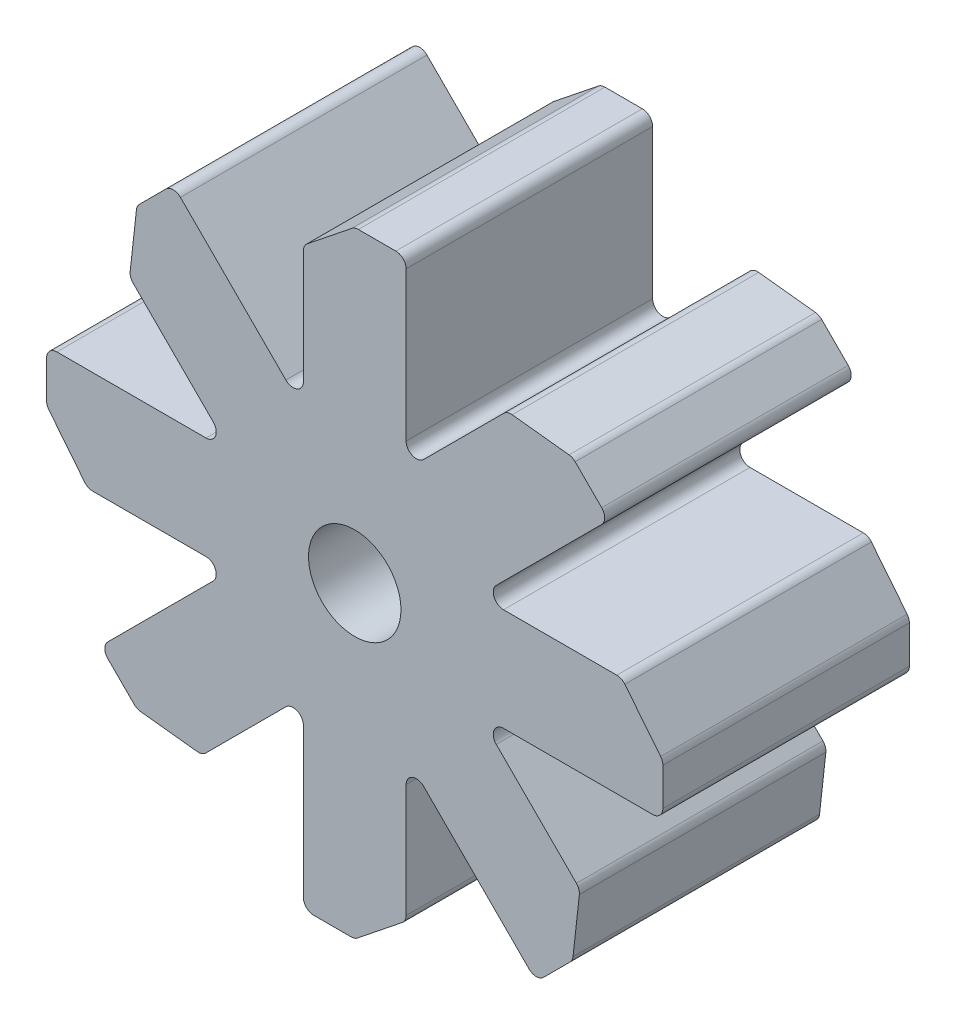
from build123d import *

# Parameters (mm, degrees)
SKETCH3_R           = 2.25
BOSS_EXTRUDE1_DEPTH = 12
INNER_EDGES_R       = 0.5
CUT_EXTRUDE2_DEPTH  = 13
OUTER_EDGES_R       = 0.5


with BuildPart() as part:
    # Sketch3 → Boss-Extrude1 (new body)
    with BuildSketch(Plane.XY):
        Polygon((-2.5, 15), (2.5, 15), (2.5, 6.035533906), (8.838834765, 12.374368671), (12.374368671, 8.838834765), (6.035533906, 2.5), (15, 2.5), (15, -2.5), (6.035533906, -2.5), (12.374368671, -8.838834765), (8.838834765, -12.374368671), (2.5, -6.035533906), (2.5, -15), (-2.5, -15), (-2.5, -6.035533906), (-8.838834765, -12.374368671), (-12.374368671, -8.838834765), (-6.035533906, -2.5), (-15, -2.5), (-15, 2.5), (-6.035533906, 2.5), (-12.374368671, 8.838834765), (-8.838834765, 12.374368671), (-2.5, 6.035533906), align=None)
        Circle(SKETCH3_R, mode=Mode.SUBTRACT)
    extrude(amount=BOSS_EXTRUDE1_DEPTH)

    # Inner Edges
    inner_edges_edges = [part.edges().sort_by_distance(p)[0] for p in [
        (6.035533906, 2.5, 6),
        (6.035533906, -2.5, 6),
        (2.5, -6.035533906, 6),
        (-2.5, -6.035533906, 6),
        (-6.035533906, -2.5, 6),
        (-6.035533906, 2.5, 6),
        (-2.5, 6.035533906, 6),
        (2.5, 6.035533906, 6),
    ]]
    fillet(inner_edges_edges, radius=INNER_EDGES_R)

    # Sketch4 → Cut-Extrude2 (cut, through all)
    with BuildSketch(Plane.XY.offset(12)):
        Polygon((10.960155108, -7.424621202), (10.606601718, -10.606601718), (12.374368671, -8.838834765), align=None)
        Polygon((13, 2.5), (15, 0), (15, 2.5), align=None)
        Polygon((8.838834765, 12.374368671), (7.424621202, 10.960155108), (10.606601718, 10.606601718), align=None)
        Polygon((-2.5, 13), (0, 15), (-2.5, 15), align=None)
        Polygon((-10.960155108, 7.424621202), (-10.606601718, 10.606601718), (-12.374368671, 8.838834765), align=None)
        Polygon((-13, -2.5), (-15, 0), (-15, -2.5), align=None)
        Polygon((-7.424621202, -10.960155108), (-10.606601718, -10.606601718), (-8.838834765, -12.374368671), align=None)
        Polygon((0, -15), (2.5, -15), (2.5, -13), align=None)
    extrude(amount=-CUT_EXTRUDE2_DEPTH, mode=Mode.SUBTRACT)

    # Outer Edges
    outer_edges_edges = [part.edges().sort_by_distance(p)[0] for p in [
        (13, 2.5, 6),
        (15, 0, 6),
        (10.606601718, 10.606601718, 6),
        (7.424621202, 10.960155108, 6),
        (-2.5, 13, 6),
        (0, 15, 6),
        (-10.960155108, 7.424621202, 6),
        (-10.606601718, 10.606601718, 6),
        (-13, -2.5, 6),
        (-15, 0, 6),
        (-10.606601718, -10.606601718, 6),
        (-7.424621202, -10.960155108, 6),
        (2.5, -13, 6),
        (0, -15, 6),
        (10.960155108, -7.424621202, 6),
        (10.606601718, -10.606601718, 6),
        (12.374368671, 8.838834765, 6),
        (15, -2.5, 6),
        (8.838834765, -12.374368671, 6),
        (-2.5, -15, 6),
        (-12.374368671, -8.838834765, 6),
        (-15, 2.5, 6),
        (-8.838834765, 12.374368671, 6),
        (2.5, 15, 6),
    ]]
    fillet(outer_edges_edges, radius=OUTER_EDGES_R)


solid = part.part
